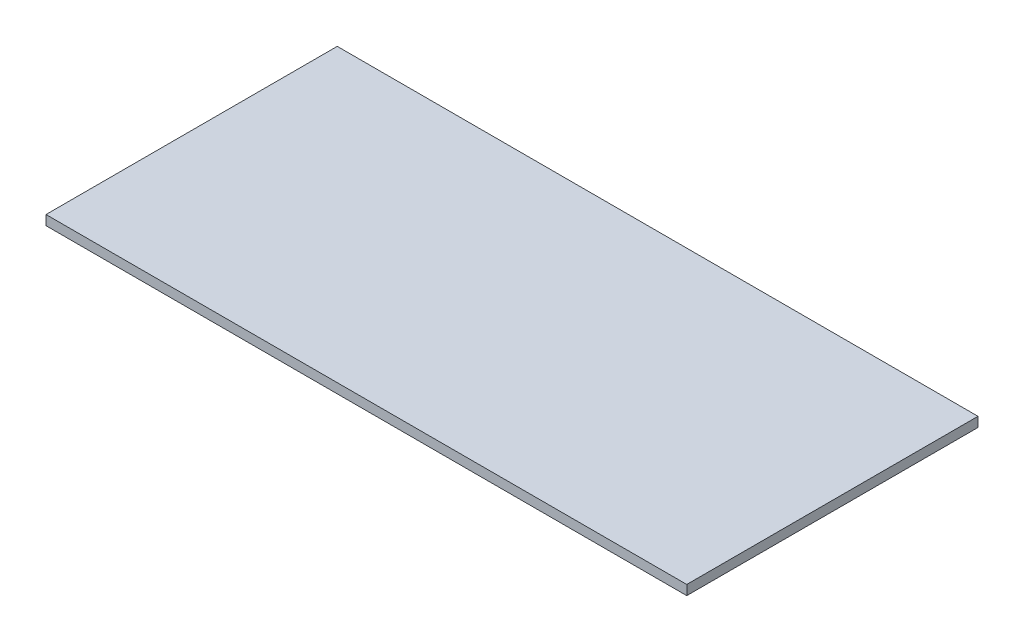
from build123d import *

# Parameters (mm, degrees)
SKETCH1_W           = 83.82
SKETCH1_H           = 38.1
BOSS_EXTRUDE1_DEPTH = 1.27


with BuildPart() as part:
    # Sketch1 → Boss-Extrude1 (new body)
    with BuildSketch(Plane(origin=(0, 0, 0), x_dir=(1, 0, 0), z_dir=(0, 1, 0))):
        with Locations((41.91, -19.05)):
            Rectangle(SKETCH1_W, SKETCH1_H)
    extrude(amount=BOSS_EXTRUDE1_DEPTH)


solid = part.part
